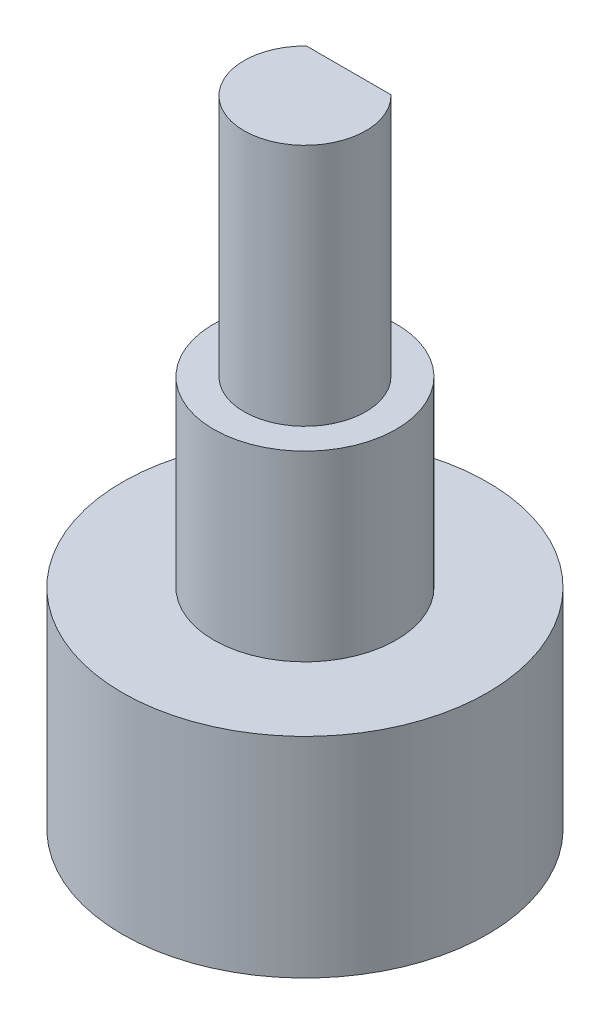
from build123d import *

# Parameters (mm, degrees)
SKETCH1_R           = 9.525
BOSS_EXTRUDE1_DEPTH = 10.922
SKETCH2_R           = 4.7625
BOSS_EXTRUDE2_DEPTH = 9.525
BOSS_EXTRUDE3_DEPTH = 12.7


with BuildPart() as part:
    # Sketch1 → Boss-Extrude1 (new body)
    with BuildSketch(Plane(origin=(0, 0, 0), x_dir=(1, 0, 0), z_dir=(0, 1, 0))):
        Circle(SKETCH1_R)
    extrude(amount=BOSS_EXTRUDE1_DEPTH)

    # Sketch2 → Boss-Extrude2 (add)
    with BuildSketch(Plane(origin=(0, 10.922, 0), x_dir=(1, 0, 0), z_dir=(0, 1, 0))):
        Circle(SKETCH2_R)
    extrude(amount=BOSS_EXTRUDE2_DEPTH)

    # Sketch3 → Boss-Extrude3 (add)
    with BuildSketch(Plane(origin=(0, 20.447, 0), x_dir=(1, 0, 0), z_dir=(0, 1, 0))):
        with BuildLine():
            Line((-2.20336765, 2.286), (2.20336765, 2.286))
            ThreePointArc((2.20336765, 2.286), (0, -3.175), (-2.20336765, 2.286))
        make_face()
    extrude(amount=BOSS_EXTRUDE3_DEPTH)


solid = part.part
